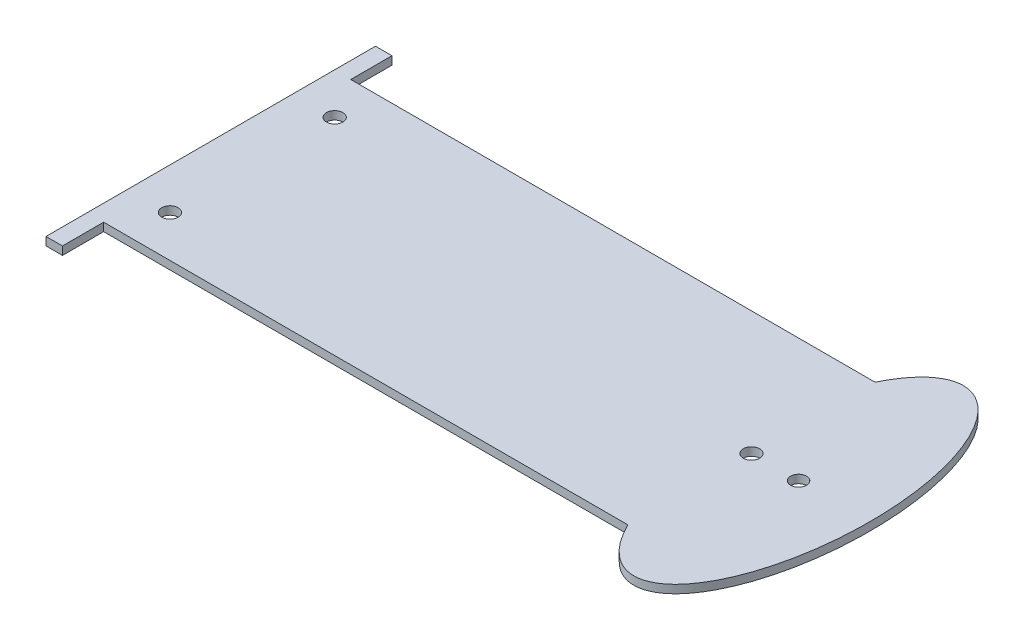
from build123d import *

# Parameters (mm, degrees)
BOSS_EXTRUDE1_DEPTH = 2.54
SKETCH2_R           = 2.54
SKETCH2_R_2         = 2.44727186
CUT_EXTRUDE1_DEPTH  = 2.54


with BuildPart() as part:
    # Sketch1 → Boss-Extrude1 (new body)
    with BuildSketch(Plane(origin=(0, 0, 0), x_dir=(1, 0, 0), z_dir=(0, 1, 0))):
        with BuildLine():
            Line((-83.020699301, -50.012469915), (78.627234219, -50.012469915))
            add(Edge.make_bspline(
                [(78.627234219, -50.012469915), (115.092471338, -124.454848136), (115.09930125, -11.906170246), (115.106131163, 100.642507644), (78.631858345, 26.187530085)],
                knots=[2.418926433, 2.418926433, 2.418926433, 4.712512983, 4.712512983, 7.006099534, 7.006099534, 7.006099534], degree=2, weights=[1, 0.411412318, 1, 0.411412318, 1]))
            Line((78.631858345, 26.187530085), (-83.020699301, 26.187530085))
            Line((-83.020699301, 26.187530085), (-83.020699301, 38.887530085))
            Line((-83.020699301, 38.887530085), (-88.100699301, 38.887530085))
            Line((-88.100699301, 38.887530085), (-88.100699301, 26.187530085))
            Line((-88.100699301, 26.187530085), (-88.100699301, -50.012469915))
            Line((-88.100699301, -50.012469915), (-88.100699301, -62.712469915))
            Line((-88.100699301, -62.712469915), (-83.020699301, -62.712469915))
            Line((-83.020699301, -62.712469915), (-83.020699301, -50.012469915))
        make_face()
    extrude(amount=BOSS_EXTRUDE1_DEPTH)

    # Sketch2 → Cut-Extrude1 (cut)
    with BuildSketch(Plane(origin=(0, 2.54, 0), x_dir=(1, 0, 0), z_dir=(0, 1, 0))):
        with Locations((-75.403543329, 13.600337103)):
            Circle(SKETCH2_R)
        with Locations((-75.403543329, -37.201288275)):
            Circle(SKETCH2_R)
        with Locations((78.629546282, -11.912469915)):
            Circle(SKETCH2_R)
        with Locations((93.149136835, -11.909961847)):
            Circle(SKETCH2_R_2)
    extrude(amount=-CUT_EXTRUDE1_DEPTH, mode=Mode.SUBTRACT)


solid = part.part
